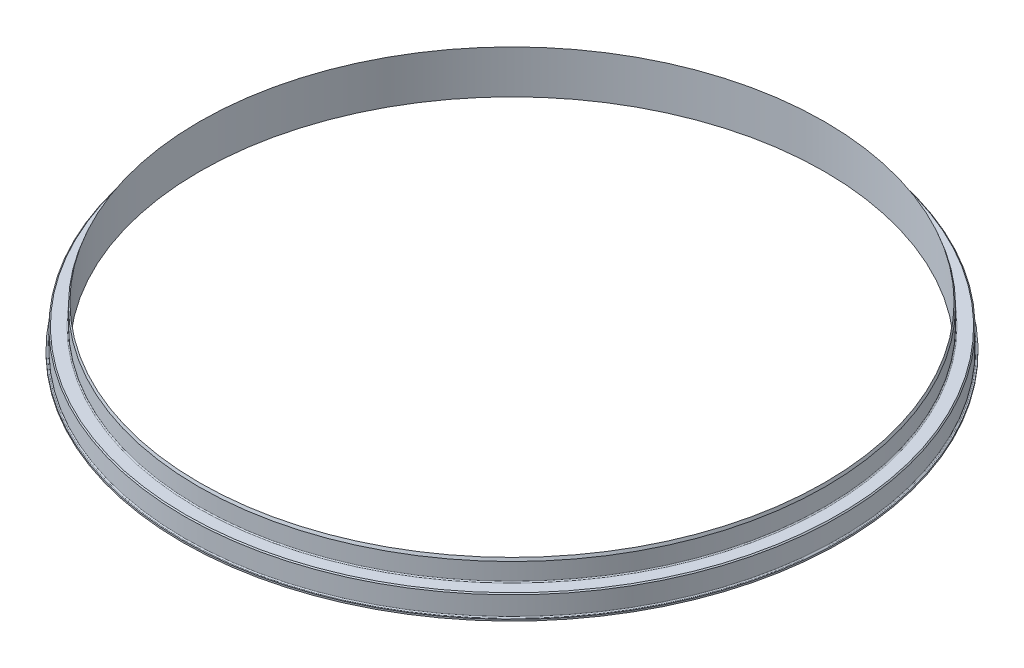
from build123d import *

# Parameters (mm, degrees)
FILLET1_R     = 0.508
CHAMFER1_SIZE = 0.508


with BuildPart() as part:
    # Sketch1 → Revolve1 (revolve)
    with BuildSketch(Plane.XY):
        Polygon((152.4, 21.082), (152.4, 0), (160.655, 0), (160.655, 0.762), (159.639, 0.762), (159.639, 10.922), (152.908, 10.922), (152.908, 19.686281471), align=None)
    revolve(axis=Axis((0, 28.738956579, 0), (0, -1, 0)))

    # Fillet1
    fillet1_edges = [part.edges().sort_by_distance(p)[0] for p in [
        (-159.639, 0.762, 0),
        (-152.908, 10.922, 0),
    ]]
    fillet(fillet1_edges, radius=FILLET1_R)

    # Chamfer1
    chamfer1_edges = [part.edges().sort_by_distance(p)[0] for p in [
        (-159.639, 10.922, 0),
    ]]
    chamfer(chamfer1_edges, length=CHAMFER1_SIZE)


solid = part.part
